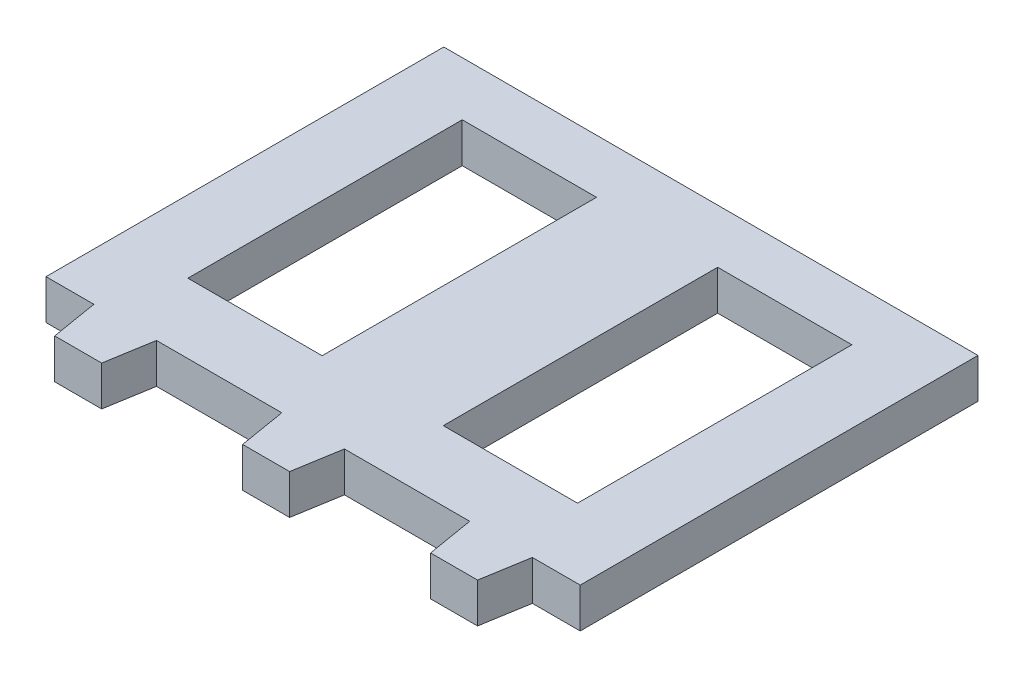
from build123d import *

# Parameters (mm, degrees)
SKETCH2_W           = 85.279590556
SKETCH2_H           = 63.5
SKETCH2_W_2         = 21.432451429
SKETCH2_H_2         = 43.79853014
BOSS_EXTRUDE1_DEPTH = 6.35


with BuildPart() as part:
    # Sketch2 → Boss-Extrude1 (new body)
    with BuildSketch(Plane(origin=(0, 0, 0), x_dir=(1, 0, 0), z_dir=(0, 1, 0))):
        Rectangle(SKETCH2_W, SKETCH2_H)
        with Locations((-20.38588495, 1.25966445)):
            Rectangle(SKETCH2_W_2, SKETCH2_H_2, mode=Mode.SUBTRACT)
        with Locations((20.38588495, 1.25966445)):
            Rectangle(SKETCH2_W_2, SKETCH2_H_2, mode=Mode.SUBTRACT)
        Polygon((-25, -31.75), (-35, -31.75), (-33.75, -39.25), (-26.25, -39.25), align=None)
        Polygon((5, -31.75), (-5, -31.75), (-3.75, -39.25), (3.75, -39.25), align=None)
        Polygon((33.75, -39.25), (35, -31.75), (25, -31.75), (26.25, -39.25), align=None)
    extrude(amount=BOSS_EXTRUDE1_DEPTH)


solid = part.part
